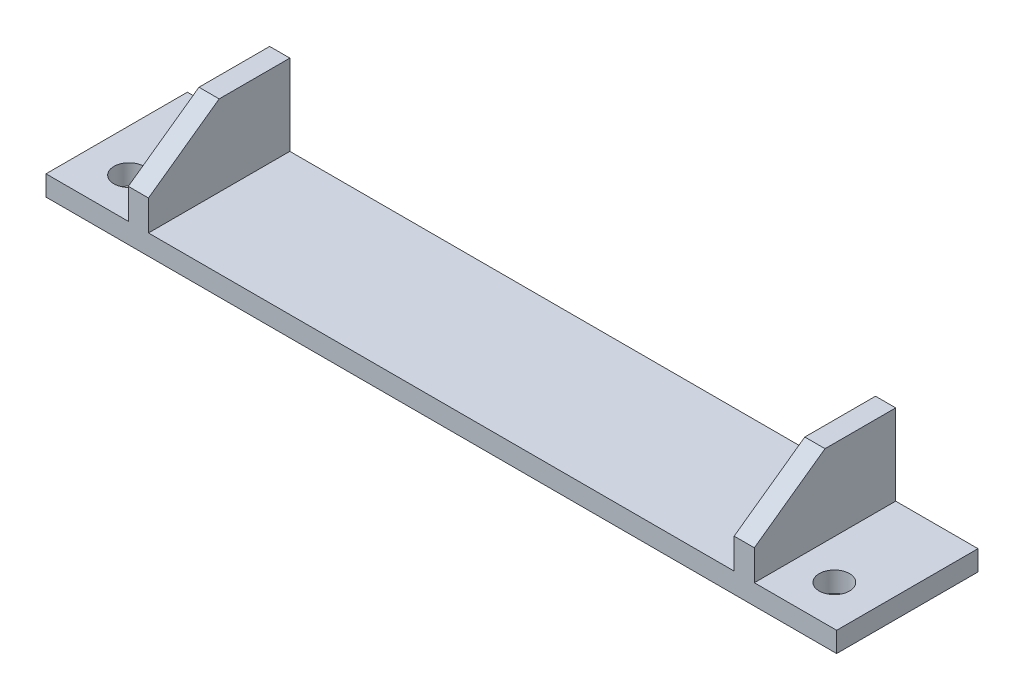
from build123d import *

# Parameters (mm, degrees)
SKETCH1_W               = 78.3
SKETCH1_H               = 14
BOSS_EXTRUDE1_DEPTH     = 2
SKETCH3_R               = 1.5
CUT_EXTRUDE2_DEPTH      = 1
CUT_EXTRUDE2_DEPTH_BACK = 3
SKETCH5_W               = 3
SKETCH5_H               = 3
BOSS_EXTRUDE2_DEPTH     = 2
SKETCH7_W               = 2
SKETCH7_H               = 14
BOSS_EXTRUDE3_DEPTH     = 8
CUT_EXTRUDE6_DEPTH      = 9.15
CUT_EXTRUDE6_DEPTH_BACK = 71.15


with BuildPart() as part:
    # Sketch1 → Boss-Extrude1 (new body)
    with BuildSketch(Plane(origin=(0, 0, 0), x_dir=(1, 0, 0), z_dir=(0, 1, 0))):
        with Locations((9.69964517, 3.832823468)):
            Rectangle(SKETCH1_W, SKETCH1_H)
    extrude(amount=BOSS_EXTRUDE1_DEPTH)

    # Sketch3 → Cut-Extrude2 (cut, two sides)
    with BuildSketch(Plane(origin=(0, 2, 0), x_dir=(1, 0, 0), z_dir=(0, 1, 0))) as cut_extrude2_sk:
        with Locations((-25.22535483, 0.832823468)):
            Circle(SKETCH3_R)
        with Locations((44.62464517, 0.832823468)):
            Circle(SKETCH3_R)
    extrude(amount=CUT_EXTRUDE2_DEPTH, mode=Mode.SUBTRACT)
    extrude(cut_extrude2_sk.sketch, amount=-CUT_EXTRUDE2_DEPTH_BACK, mode=Mode.SUBTRACT)

    # Sketch5 → Boss-Extrude2 (add)
    with BuildSketch(Plane.XZ):
        with Locations((-11.00035483, -9.332823468)):
            Rectangle(SKETCH5_W, SKETCH5_H)
        with Locations((30.39964517, -9.332823468)):
            Rectangle(SKETCH5_W, SKETCH5_H)
    extrude(amount=BOSS_EXTRUDE2_DEPTH)

    # Sketch7 → Boss-Extrude3 (add)
    with BuildSketch(Plane(origin=(0, 2, 0), x_dir=(1, 0, 0), z_dir=(0, 1, 0))):
        with Locations((39.69964517, 3.832823468)):
            Rectangle(SKETCH7_W, SKETCH7_H)
        with Locations((-20.30035483, 3.832823468)):
            Rectangle(SKETCH7_W, SKETCH7_H)
    extrude(amount=BOSS_EXTRUDE3_DEPTH)

    # Sketch9 → Cut-Extrude6 (cut, two sides)
    with BuildSketch(Plane.ZY.offset(21.30035483)) as cut_extrude6_sk:
        Polygon((3.167176532, 10), (3.167176532, 5), (-3.832823468, 10), align=None)
    extrude(amount=CUT_EXTRUDE6_DEPTH, mode=Mode.SUBTRACT)
    extrude(cut_extrude6_sk.sketch, amount=-CUT_EXTRUDE6_DEPTH_BACK, mode=Mode.SUBTRACT)


solid = part.part
